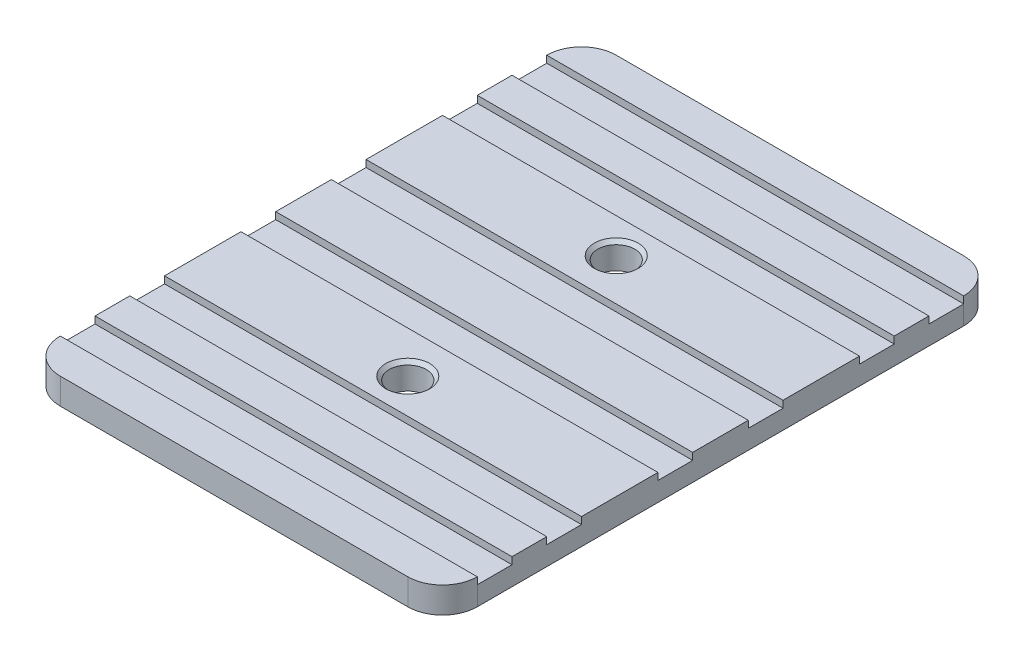
from build123d import *

# Parameters (mm, degrees)
SKETCH1_W                         = 76.2
SKETCH1_H                         = 101.6
BOSS_EXTRUDE1_DEPTH               = 4.7625
F_1_4_CLEARANCE_HOLE1_D           = 6.7564
F_1_4_CLEARANCE_HOLE1_CSINK_D     = 8.0264
F_1_4_CLEARANCE_HOLE1_CSINK_ANGLE = 90
FILLET1_R                         = 6.35
SKETCH7_W                         = 76.2
SKETCH7_H                         = 6.35
CUT_EXTRUDE1_DEPTH                = 1.27


with BuildPart() as part:
    # Sketch1 → Boss-Extrude1 (new body)
    with BuildSketch(Plane(origin=(0, 0, 0), x_dir=(1, 0, 0), z_dir=(0, 1, 0))):
        with Locations((38.1, -50.8)):
            Rectangle(SKETCH1_W, SKETCH1_H)
    extrude(amount=BOSS_EXTRUDE1_DEPTH)

    # 1/4 Clearance Hole1 (through all)
    with Locations(Plane(origin=(0, 4.7625, 0), x_dir=(1, 0, 0), z_dir=(0, 1, 0))):
        with Locations((38.1, -69.85), (38.1, -31.75)):
            CounterSinkHole(F_1_4_CLEARANCE_HOLE1_D / 2, F_1_4_CLEARANCE_HOLE1_CSINK_D / 2, counter_sink_angle=F_1_4_CLEARANCE_HOLE1_CSINK_ANGLE)

    # Fillet1
    fillet1_edges = [part.edges().sort_by_distance(p)[0] for p in [
        (0, 2.38125, 0),
        (76.2, 2.38125, 0),
        (76.2, 2.38125, 101.6),
        (0, 2.38125, 101.6),
    ]]
    fillet(fillet1_edges, radius=FILLET1_R)

    # Sketch7 → Cut-Extrude1 (cut)
    with BuildSketch(Plane(origin=(0, 4.7625, 0), x_dir=(1, 0, 0), z_dir=(0, 1, 0))):
        with Locations((38.1, -9.525)):
            Rectangle(SKETCH7_W, SKETCH7_H)
        with Locations((38.1, -42.545)):
            Rectangle(SKETCH7_W, SKETCH7_H)
        with Locations((38.1, -59.055)):
            Rectangle(SKETCH7_W, SKETCH7_H)
        with Locations((38.1, -92.075)):
            Rectangle(SKETCH7_W, SKETCH7_H)
        with Locations((38.1, -79.375)):
            Rectangle(SKETCH7_W, SKETCH7_H)
        with Locations((38.1, -22.225)):
            Rectangle(SKETCH7_W, SKETCH7_H)
    extrude(amount=-CUT_EXTRUDE1_DEPTH, mode=Mode.SUBTRACT)


solid = part.part
